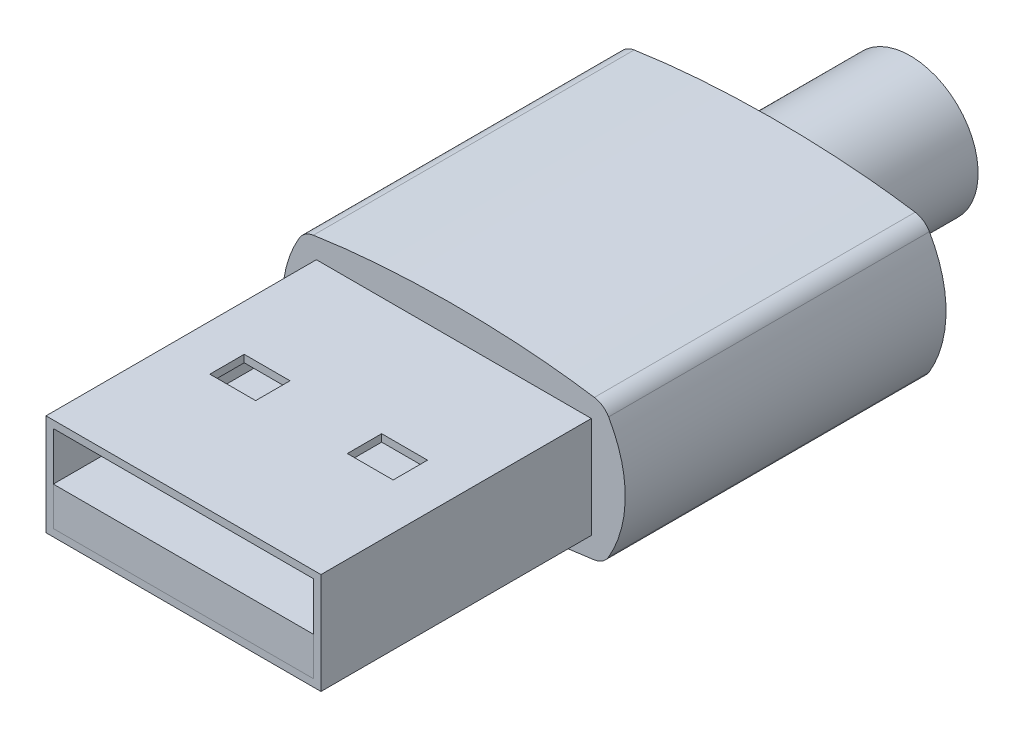
from build123d import *

# Parameters (mm, degrees)
SKETCH1_W           = 12
SKETCH1_H           = 4.42
SKETCH1_W_2         = 11.36
SKETCH1_H_2         = 2.1
BOSS_EXTRUDE1_DEPTH = 11.8
BOSS_EXTRUDE3_DEPTH = 14
SKETCH3_R           = 2.96
BOSS_EXTRUDE4_DEPTH = 5.92
CUT_EXTRUDE1_REACH  = 35.088
SKETCH4_W           = 2
SKETCH4_H           = 1.5


with BuildPart() as part:
    # Sketch1 → Boss-Extrude1 (new body)
    with BuildSketch(Plane.XY):
        Rectangle(SKETCH1_W, SKETCH1_H)
        with Locations((0, 0.84)):
            Rectangle(SKETCH1_W_2, SKETCH1_H_2, mode=Mode.SUBTRACT)
    extrude(amount=-BOSS_EXTRUDE1_DEPTH)

    # Sketch2 → Boss-Extrude3 (add)
    with BuildSketch(Plane(origin=(0, 0, -11.8), x_dir=(-1, 0, 0), z_dir=(0, 0, -1))):
        with BuildLine():
            ThreePointArc((-6.132053571, 3.071220572), (-6.491568803, 2.929374125), (-6.754360741, 2.64598038))
            add(Edge.make_bspline(
                [(-6.754360741, 2.64598038), (-8.283596649, 0), (-6.754360741, -2.64598038)],
                knots=[5.839065971, 5.839065971, 5.839065971, 6.727304644, 6.727304644, 6.727304644], degree=2, weights=[1, 0.902989404, 1]))
            ThreePointArc((-6.754360741, -2.64598038), (-6.491568803, -2.929374125), (-6.132053571, -3.071220572))
            add(Edge.make_bspline(
                [(-6.132053571, -3.071220572), (0, -4.011467008), (6.132053571, -3.071220572)],
                knots=[1.065418499, 1.065418499, 1.065418499, 2.076174155, 2.076174155, 2.076174155], degree=2, weights=[1, 0.874991616, 1]))
            ThreePointArc((6.132053571, -3.071220572), (6.491568803, -2.929374125), (6.754360741, -2.64598038))
            add(Edge.make_bspline(
                [(6.754360741, -2.64598038), (8.283596649, 0), (6.754360741, 2.64598038)],
                knots=[2.697473317, 2.697473317, 2.697473317, 3.58571199, 3.58571199, 3.58571199], degree=2, weights=[1, 0.902989404, 1]))
            ThreePointArc((6.754360741, 2.64598038), (6.491568803, 2.929374125), (6.132053571, 3.071220572))
            add(Edge.make_bspline(
                [(6.132053571, 3.071220572), (0, 4.011467008), (-6.132053571, 3.071220572)],
                knots=[4.207011152, 4.207011152, 4.207011152, 5.217766808, 5.217766808, 5.217766808], degree=2, weights=[1, 0.874991616, 1]))
        make_face()
    extrude(amount=BOSS_EXTRUDE3_DEPTH)

    # Sketch3 → Boss-Extrude4 (add)
    with BuildSketch(Plane(origin=(0, 0, -25.8), x_dir=(-1, 0, 0), z_dir=(0, 0, -1))):
        Circle(SKETCH3_R)
    extrude(amount=BOSS_EXTRUDE4_DEPTH)

    # Sketch4 → Cut-Extrude1 (cut, up to next)
    with BuildSketch(Plane(origin=(0, 2.21, 0), x_dir=(1, 0, 0), z_dir=(0, 1, 0)), mode=Mode.PRIVATE) as cut_extrude1_sk1:
        with Locations((3, 5.9)):
            Rectangle(SKETCH4_W, SKETCH4_H)
    cut_extrude1_tool1 = extrude(cut_extrude1_sk1.sketch, amount=-CUT_EXTRUDE1_REACH, mode=Mode.PRIVATE) & part.part
    # Sketch4 → Cut-Extrude1 (cut, up to next)
    with BuildSketch(Plane(origin=(0, 2.21, 0), x_dir=(1, 0, 0), z_dir=(0, 1, 0)), mode=Mode.PRIVATE) as cut_extrude1_sk2:
        with Locations((-3, 5.9)):
            Rectangle(SKETCH4_W, SKETCH4_H)
    cut_extrude1_tool2 = extrude(cut_extrude1_sk2.sketch, amount=-CUT_EXTRUDE1_REACH, mode=Mode.PRIVATE) & part.part
    add(cut_extrude1_tool1.solids().sort_by_distance((3, 2.21, -5.9))[0], mode=Mode.SUBTRACT)
    add(cut_extrude1_tool2.solids().sort_by_distance((-3, 2.21, -5.9))[0], mode=Mode.SUBTRACT)


solid = part.part
